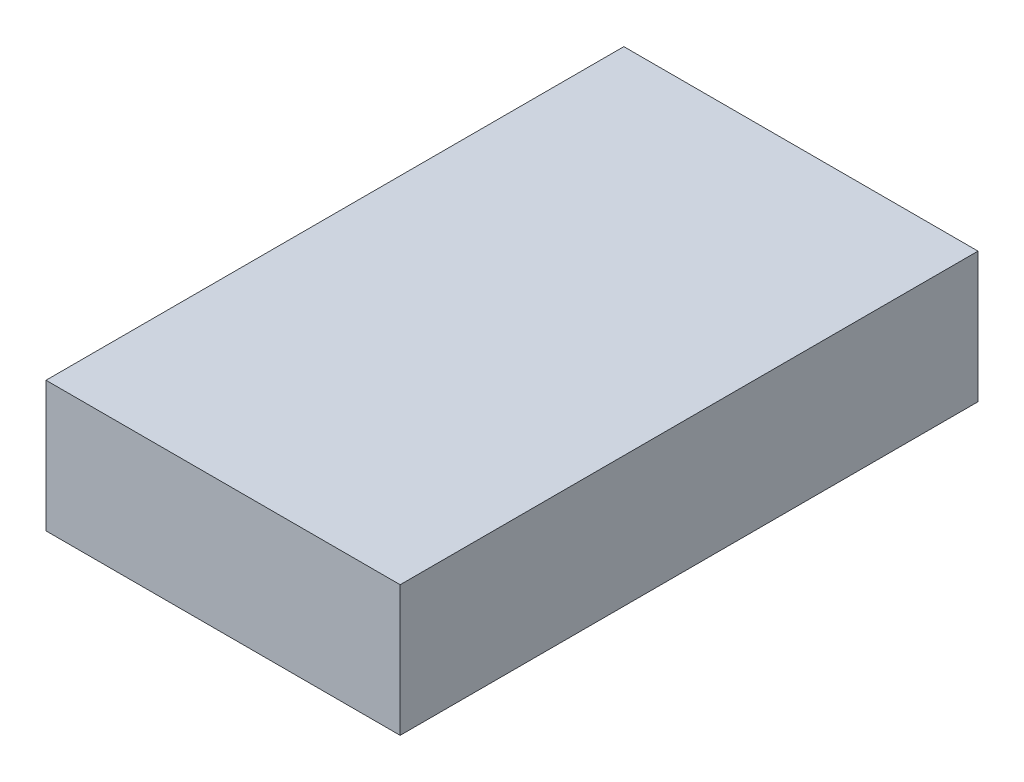
from build123d import *

# Parameters (mm, degrees)
SKETCH1_W           = 48.26
SKETCH1_H           = 78.74
BOSS_EXTRUDE1_DEPTH = 17.78


with BuildPart() as part:
    # Sketch1 → Boss-Extrude1 (new body)
    with BuildSketch(Plane(origin=(0, 0, 0), x_dir=(1, 0, 0), z_dir=(0, 1, 0))):
        with Locations((24.13, 39.37)):
            Rectangle(SKETCH1_W, SKETCH1_H)
    extrude(amount=BOSS_EXTRUDE1_DEPTH)


solid = part.part
